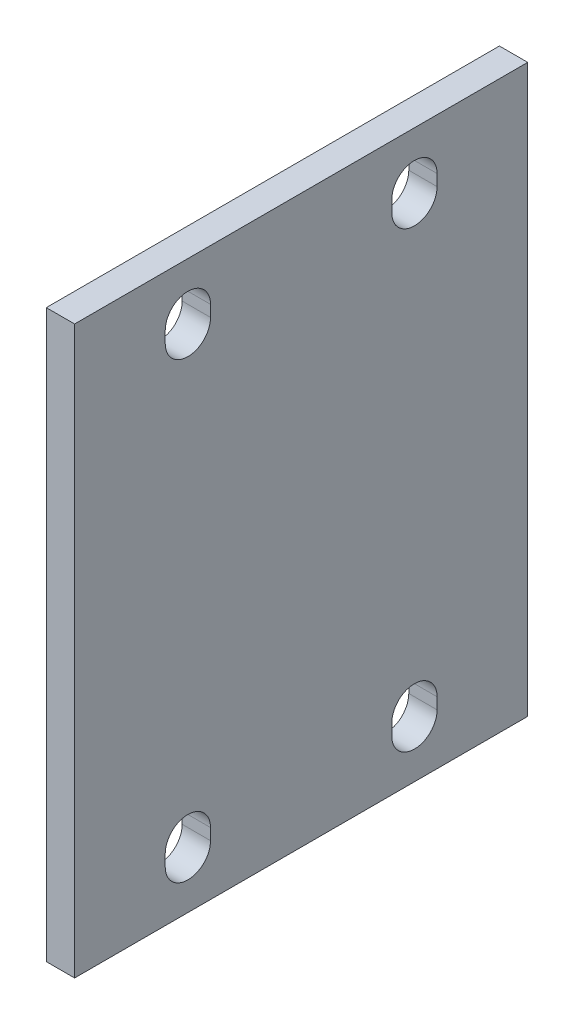
from build123d import *

# Parameters (mm, degrees)
SKETCH1_W           = 80
SKETCH1_H           = 100
SKETCH1_R           = 21.5
SKETCH1_R_2         = 14
SKETCH1_R_3         = 2
BOSS_EXTRUDE1_DEPTH = 5
SKETCH3_W           = 80
SKETCH3_H           = 55.127756358
CUT_EXTRUDE1_DEPTH  = 6


with BuildPart() as part:
    # Sketch1 → Boss-Extrude1 (new body)
    with BuildSketch(Plane(origin=(0, 0, 0), x_dir=(0, 0, -1), z_dir=(1, 0, 0))):
        Rectangle(SKETCH1_W, SKETCH1_H)
        with BuildLine():
            ThreePointArc((24, -39), (20, -35), (16, -39))
            Line((16, -39), (16, -41))
            ThreePointArc((16, -41), (20, -45), (24, -41))
            Line((24, -41), (24, -39))
        make_face(mode=Mode.SUBTRACT)
        with BuildLine():
            ThreePointArc((-24, 39), (-20, 35), (-16, 39))
            Line((-16, 39), (-16, 41))
            ThreePointArc((-16, 41), (-20, 45), (-24, 41))
            Line((-24, 41), (-24, 39))
        make_face(mode=Mode.SUBTRACT)
        with BuildLine():
            Line((24, 41), (24, 39))
            ThreePointArc((24, 39), (20, 35), (16, 39))
            Line((16, 39), (16, 41))
            ThreePointArc((16, 41), (20, 45), (24, 41))
        make_face(mode=Mode.SUBTRACT)
        with BuildLine():
            Line((-24, -41), (-24, -39))
            ThreePointArc((-24, -39), (-20, -35), (-16, -39))
            Line((-16, -39), (-16, -41))
            ThreePointArc((-16, -41), (-20, -45), (-24, -41))
        make_face(mode=Mode.SUBTRACT)
        with BuildLine():
            Line((40, -50), (-40, -50))
            Line((-40, -50), (-18.452584301, -86.034134882))
            ThreePointArc((-18.452584301, -86.034134882), (-5.72361064, -54.275852702), (21.5, -75))
            ThreePointArc((21.5, -75), (20.724147298, -80.72361064), (18.452584301, -86.034134882))
            Line((18.452584301, -86.034134882), (40, -50))
        make_face()
        with Locations((0, -75)):
            Circle(SKETCH1_R)
        with Locations((0, -75)):
            Circle(SKETCH1_R_2, mode=Mode.SUBTRACT)
        with Locations((17.5, -75)):
            Circle(SKETCH1_R_3, mode=Mode.SUBTRACT)
        with Locations((0, -92.5)):
            Circle(SKETCH1_R_3, mode=Mode.SUBTRACT)
        with Locations((-17.5, -75)):
            Circle(SKETCH1_R_3, mode=Mode.SUBTRACT)
        with Locations((0, -57.5)):
            Circle(SKETCH1_R_3, mode=Mode.SUBTRACT)
    extrude(amount=BOSS_EXTRUDE1_DEPTH)

    # Sketch3 → Cut-Extrude1 (cut, through all)
    with BuildSketch(Plane(origin=(5, 0, 0), x_dir=(0, 0, -1), z_dir=(1, 0, 0))):
        with Locations((0, -77.563878179)):
            Rectangle(SKETCH3_W, SKETCH3_H)
    extrude(amount=-CUT_EXTRUDE1_DEPTH, mode=Mode.SUBTRACT)


solid = part.part
